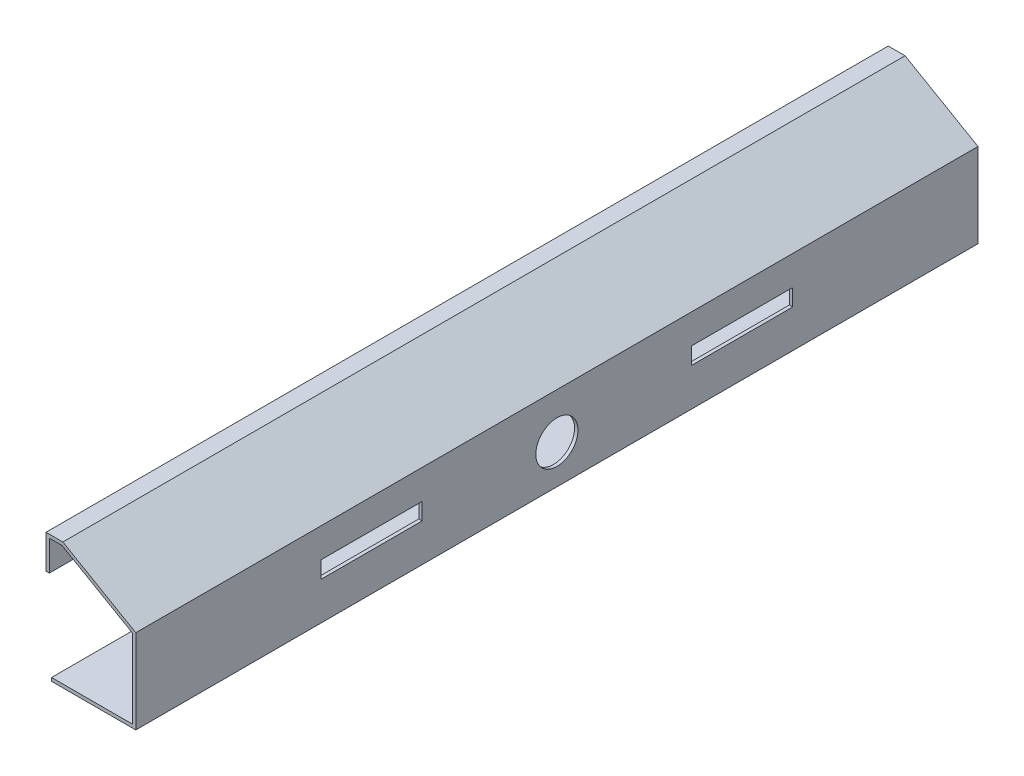
from build123d import *

# Parameters (mm, degrees)
BOSS_EXTRUDE1_DEPTH = 500
SKETCH2_R           = 12.5
CUT_EXTRUDE1_DEPTH  = 54.301270189
SKETCH3_W           = 60
SKETCH3_H           = 10
CUT_EXTRUDE2_DEPTH  = 2
SKETCH4_W           = 500
SKETCH4_H           = 20
BOSS_EXTRUDE2_DEPTH = 2


with BuildPart() as part:
    # Sketch1 → Boss-Extrude1 (new body)
    with BuildSketch(Plane.XY):
        Polygon((0, 0), (-43.301270189, 25), (-53.301270189, 25), (-53.301270189, 23), (-43.837168574, 23), (-2, -1.154700538), (-2, -48), (-50, -48), (-50, -50), (0, -50), align=None)
    extrude(amount=BOSS_EXTRUDE1_DEPTH)

    # Sketch2 → Cut-Extrude1 (cut, through all)
    with BuildSketch(Plane(origin=(0, 0, 0), x_dir=(0, 0, -1), z_dir=(1, 0, 0))):
        with Locations((-250, -27)):
            Circle(SKETCH2_R)
    extrude(amount=-CUT_EXTRUDE1_DEPTH, mode=Mode.SUBTRACT)

    # Sketch3 → Cut-Extrude2 (cut)
    with BuildSketch(Plane(origin=(0, 0, 0), x_dir=(0, 0, -1), z_dir=(1, 0, 0))):
        with Locations((-140, -22.5)):
            Rectangle(SKETCH3_W, SKETCH3_H)
        with Locations((-360, -22.5)):
            Rectangle(SKETCH3_W, SKETCH3_H)
    extrude(amount=-CUT_EXTRUDE2_DEPTH, mode=Mode.SUBTRACT)

    # Sketch4 → Boss-Extrude2 (add)
    with BuildSketch(Plane.ZY.offset(53.301270189)):
        with Locations((250, 15)):
            Rectangle(SKETCH4_W, SKETCH4_H)
    extrude(amount=-BOSS_EXTRUDE2_DEPTH)


solid = part.part
